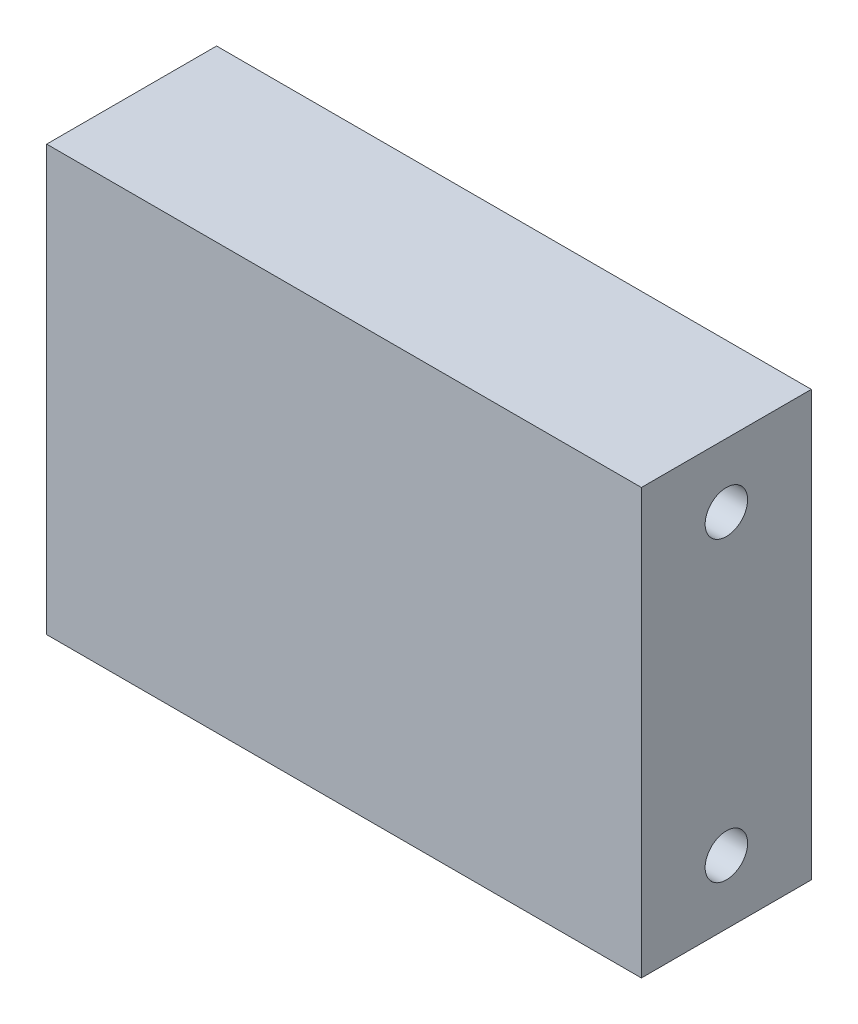
from build123d import *

# Parameters (mm, degrees)
SKETCH1_W           = 177.8
SKETCH1_H           = 50.8
BOSS_EXTRUDE1_DEPTH = 127
SKETCH3_R           = 6.35
CUT_EXTRUDE1_DEPTH  = 178.8


with BuildPart() as part:
    # Sketch1 → Boss-Extrude1 (new body)
    with BuildSketch(Plane(origin=(0, 0, 0), x_dir=(1, 0, 0), z_dir=(0, 1, 0))):
        with Locations((88.9, 25.4)):
            Rectangle(SKETCH1_W, SKETCH1_H)
    extrude(amount=BOSS_EXTRUDE1_DEPTH)

    # Sketch3 → Cut-Extrude1 (cut, through all)
    with BuildSketch(Plane.ZY):
        with Locations((-25.4, 19.05)):
            Circle(SKETCH3_R)
        with Locations((-25.4, 107.95)):
            Circle(SKETCH3_R)
    extrude(amount=-CUT_EXTRUDE1_DEPTH, mode=Mode.SUBTRACT)


solid = part.part
